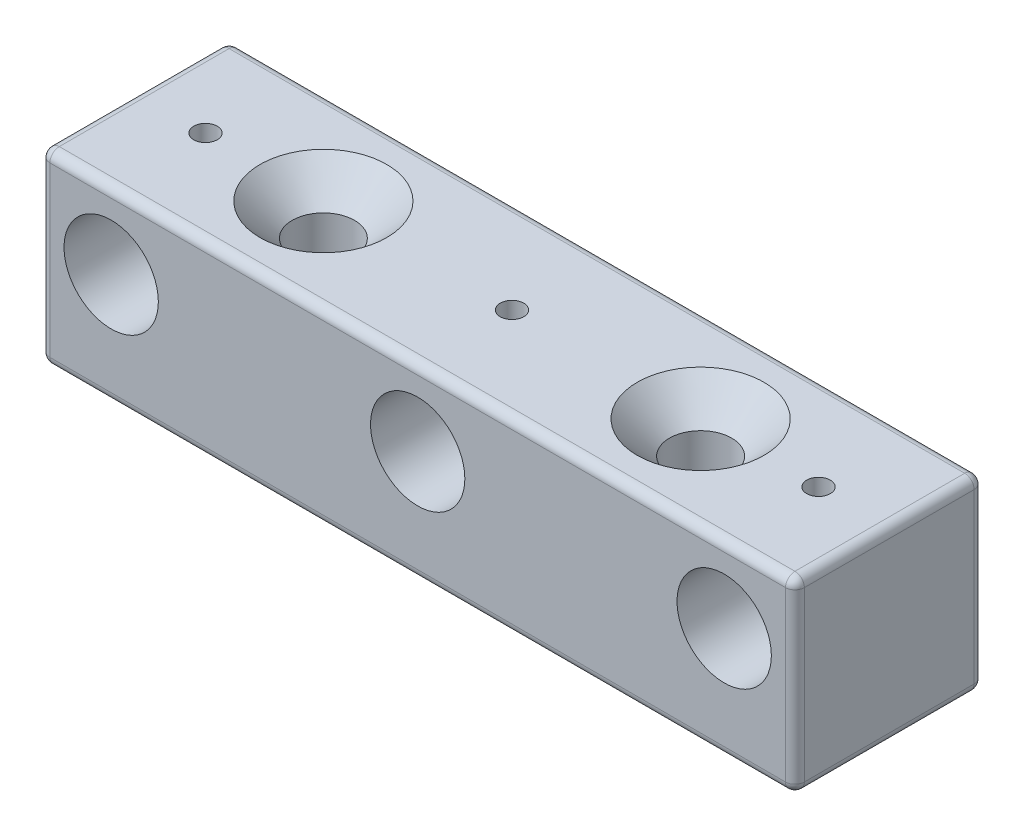
from build123d import *

# Parameters (mm, degrees)
SKETCH1_W                     = 80
SKETCH1_H                     = 20
BOSS_EXTRUDE1_DEPTH           = 19.85
CUT_EXTRUDE1_REACH            = 86.818
SKETCH2_R                     = 3.1
SKETCH3_R                     = 5
CUT_EXTRUDE2_DEPTH            = 15
FILLET1_R                     = 1
CSK_FOR_M6_SFHCS1_D           = 6.6
CSK_FOR_M6_SFHCS1_DEPTH       = 19.85
CSK_FOR_M6_SFHCS1_CSINK_D     = 13.44
CSK_FOR_M6_SFHCS1_CSINK_ANGLE = 90
M3X0_5_TAPPED_HOLE1_REACH     = 86.818
M3X0_5_TAPPED_HOLE1_BORE_R    = 1.25


with BuildPart() as part:
    # Sketch1 → Boss-Extrude1 (new body)
    with BuildSketch(Plane(origin=(0, 0, 0), x_dir=(1, 0, 0), z_dir=(0, 1, 0))):
        with Locations((40, 10)):
            Rectangle(SKETCH1_W, SKETCH1_H)
    extrude(amount=BOSS_EXTRUDE1_DEPTH)

    # Sketch2 → Cut-Extrude1 (cut, up to next)
    with BuildSketch(Plane(origin=(0, 19.85, 0), x_dir=(1, 0, 0), z_dir=(0, 1, 0)), mode=Mode.PRIVATE) as cut_extrude1_sk1:
        with Locations(Location((20, 10, 0), (0, 0, 270))):
            Circle(SKETCH2_R)
    cut_extrude1_tool1 = extrude(cut_extrude1_sk1.sketch, amount=-CUT_EXTRUDE1_REACH, mode=Mode.PRIVATE) & part.part
    # Sketch2 → Cut-Extrude1 (cut, up to next)
    with BuildSketch(Plane(origin=(0, 19.85, 0), x_dir=(1, 0, 0), z_dir=(0, 1, 0)), mode=Mode.PRIVATE) as cut_extrude1_sk2:
        with Locations(Location((60, 10, 0), (0, 0, 270))):
            Circle(SKETCH2_R)
    cut_extrude1_tool2 = extrude(cut_extrude1_sk2.sketch, amount=-CUT_EXTRUDE1_REACH, mode=Mode.PRIVATE) & part.part
    add(cut_extrude1_tool1.solids().sort_by_distance((20, 19.85, -10))[0], mode=Mode.SUBTRACT)
    add(cut_extrude1_tool2.solids().sort_by_distance((60, 19.85, -10))[0], mode=Mode.SUBTRACT)

    # Sketch3 → Cut-Extrude2 (cut)
    with BuildSketch(Plane.XY):
        with Locations((7.5, 11.85)):
            Circle(SKETCH3_R)
        with Locations((72.5, 11.85)):
            Circle(SKETCH3_R)
        with Locations((40, 11.85)):
            Circle(SKETCH3_R)
    extrude(amount=-CUT_EXTRUDE2_DEPTH, mode=Mode.SUBTRACT)

    # Fillet1
    fillet1_edges = [part.edges().sort_by_distance(p)[0] for p in [
        (80, 19.85, -10),
        (40, 19.85, -20),
        (0, 19.85, -10),
        (40, 0, -20),
        (80, 0, -10),
        (40, 0, 0),
        (0, 0, -10),
        (40, 19.85, 0),
        (0, 9.925, -20),
        (80, 9.925, -20),
        (80, 9.925, 0),
        (0, 9.925, 0),
    ]]
    fillet(fillet1_edges, radius=FILLET1_R)

    # CSK for M6 SFHCS1
    with Locations(Plane(origin=(20, 19.85, -10), x_dir=(0, 0, 1), z_dir=(0, 1, 0))):
        with Locations((0, 0), (0, 40)):
            CounterSinkHole(CSK_FOR_M6_SFHCS1_D / 2, CSK_FOR_M6_SFHCS1_CSINK_D / 2, depth=CSK_FOR_M6_SFHCS1_DEPTH, counter_sink_angle=CSK_FOR_M6_SFHCS1_CSINK_ANGLE)

    # M3x0.5 Tapped Hole1 bore → M3x0.5 Tapped Hole1 (cut, up to next)
    with BuildSketch(Plane(origin=(0, 19.85, 0), x_dir=(1, 0, 0), z_dir=(0, 1, 0)), mode=Mode.PRIVATE) as m3x0_5_tapped_hole1_sk1:
        with Locations((7.5, 10)):
            Circle(M3X0_5_TAPPED_HOLE1_BORE_R)
    m3x0_5_tapped_hole1_tool1 = extrude(m3x0_5_tapped_hole1_sk1.sketch, amount=-M3X0_5_TAPPED_HOLE1_REACH, mode=Mode.PRIVATE) & part.part
    # M3x0.5 Tapped Hole1 bore → M3x0.5 Tapped Hole1 (cut, up to next)
    with BuildSketch(Plane(origin=(0, 19.85, 0), x_dir=(1, 0, 0), z_dir=(0, 1, 0)), mode=Mode.PRIVATE) as m3x0_5_tapped_hole1_sk2:
        with Locations((40, 10)):
            Circle(M3X0_5_TAPPED_HOLE1_BORE_R)
    m3x0_5_tapped_hole1_tool2 = extrude(m3x0_5_tapped_hole1_sk2.sketch, amount=-M3X0_5_TAPPED_HOLE1_REACH, mode=Mode.PRIVATE) & part.part
    # M3x0.5 Tapped Hole1 bore → M3x0.5 Tapped Hole1 (cut, up to next)
    with BuildSketch(Plane(origin=(0, 19.85, 0), x_dir=(1, 0, 0), z_dir=(0, 1, 0)), mode=Mode.PRIVATE) as m3x0_5_tapped_hole1_sk3:
        with Locations((72.5, 10)):
            Circle(M3X0_5_TAPPED_HOLE1_BORE_R)
    m3x0_5_tapped_hole1_tool3 = extrude(m3x0_5_tapped_hole1_sk3.sketch, amount=-M3X0_5_TAPPED_HOLE1_REACH, mode=Mode.PRIVATE) & part.part
    add(m3x0_5_tapped_hole1_tool1.solids().sort_by_distance((7.5, 19.85, -10))[0], mode=Mode.SUBTRACT)
    add(m3x0_5_tapped_hole1_tool2.solids().sort_by_distance((40, 19.85, -10))[0], mode=Mode.SUBTRACT)
    add(m3x0_5_tapped_hole1_tool3.solids().sort_by_distance((72.5, 19.85, -10))[0], mode=Mode.SUBTRACT)


solid = part.part
